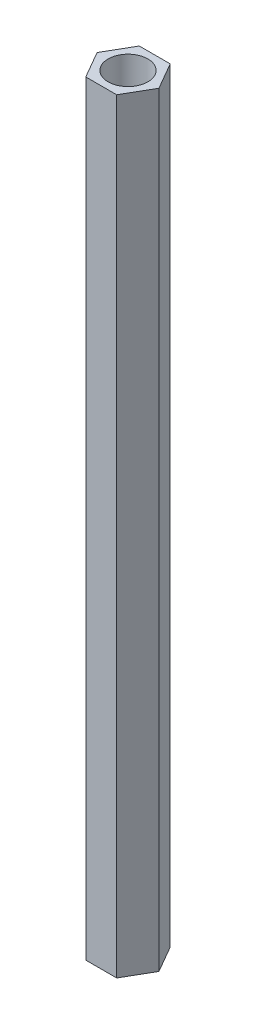
from build123d import *

# Parameters (mm, degrees)
EXTRUDE_1_DEPTH     = 100
SKETCH_2_R          = 2.6
CUT_EXTRUDE_1_DEPTH = 101
SKETCH_3_R          = 2.6
EXTRUDE_2_DEPTH     = 80


with BuildPart() as part:
    # 草图1 → 凸台-拉伸1 (new body)
    with BuildSketch(Plane(origin=(0, 0, 0), x_dir=(1, 0, 0), z_dir=(0, 1, 0))):
        Polygon((4.041451884, 0), (2.020725942, 3.5), (-2.020725942, 3.5), (-4.041451884, 0), (-2.020725942, -3.5), (2.020725942, -3.5), align=None)
    extrude(amount=EXTRUDE_1_DEPTH)

    # 草图2 → 切除-拉伸1 (cut, through all)
    with BuildSketch(Plane(origin=(0, 100, 0), x_dir=(1, 0, 0), z_dir=(0, 1, 0))):
        Circle(SKETCH_2_R)
    extrude(amount=-CUT_EXTRUDE_1_DEPTH, mode=Mode.SUBTRACT)

    # 草图3 → 凸台-拉伸2 (add)
    with BuildSketch(Plane(origin=(0, 90, 0), x_dir=(1, 0, 0), z_dir=(0, 1, 0))):
        Circle(SKETCH_3_R)
    extrude(amount=-EXTRUDE_2_DEPTH)


solid = part.part
